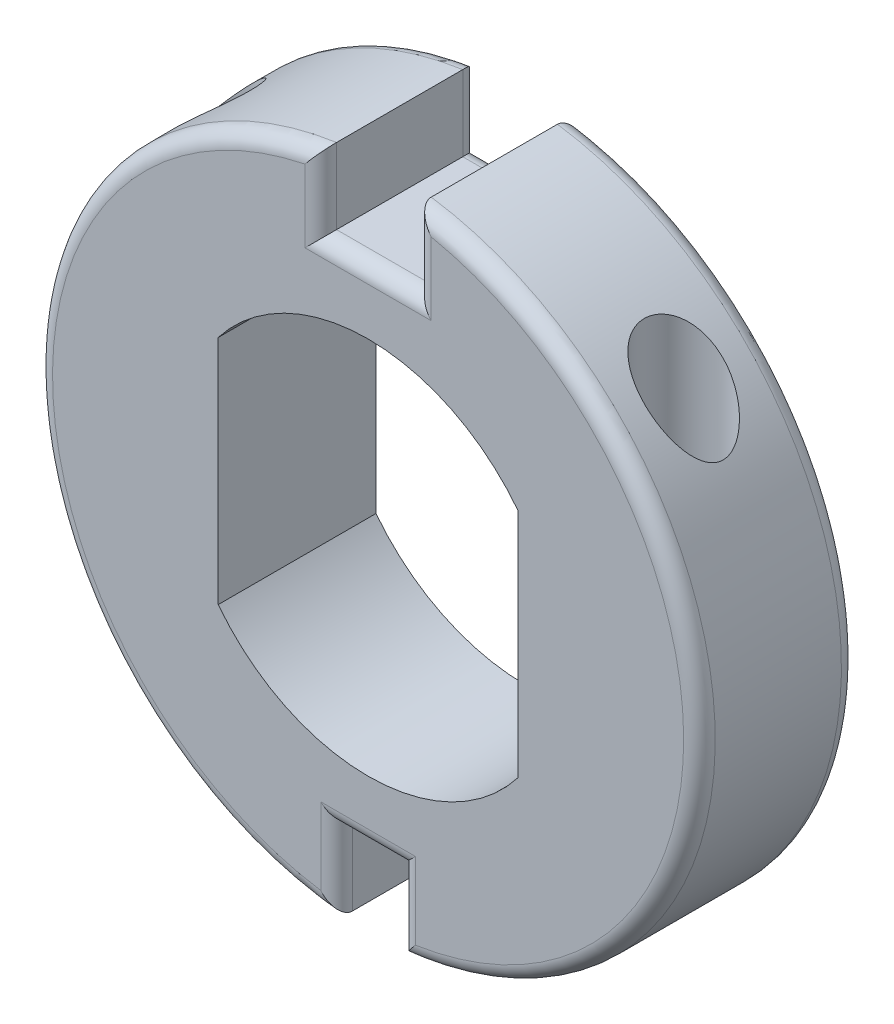
from build123d import *

# Parameters (mm, degrees)
BOSS_EXTRU_1_DEPTH           = 10
ENL_V_MAT_EXTRU_1_DEPTH      = 20
ENL_V_MAT_EXTRU_1_DEPTH_BACK = 10
ESQUISSE2_R                  = 1.25
ENL_V_START                  = 7.5
ESQUISSE2_5_R                = 2.5
ESQUISSE2_5_R_2              = 1.25
ENL_V_MAT_EXTRU_2_DEPTH      = 10
CONG_1_R                     = 1


with BuildPart() as part:
    # Esquisse1 → Boss.-Extru.1 (new body)
    with BuildSketch(Plane.XY):
        with BuildLine():
            Line((3, 20.784609691), (3, 16))
            Line((3, 16), (-3, 16))
            Line((-3, 16), (-3, 20.784609691))
            ThreePointArc((-3, 20.784609691), (-20.993961129, -0.503583277), (-2, -20.90454496))
            Line((-2, -20.90454496), (-2, -15.90454496))
            Line((-2, -15.90454496), (2, -15.90454496))
            Line((2, -15.90454496), (2, -20.90454496))
            ThreePointArc((2, -20.90454496), (20.993961129, -0.503583277), (3, 20.784609691))
        make_face()
        with BuildLine():
            ThreePointArc((-9.5, 7.331439149), (0, 12), (9.5, 7.331439149))
            Line((9.5, 7.331439149), (9.5, -7.331439149))
            ThreePointArc((9.5, -7.331439149), (0, -12), (-9.5, -7.331439149))
            Line((-9.5, -7.331439149), (-9.5, 7.331439149))
        make_face(mode=Mode.SUBTRACT)
    extrude(amount=BOSS_EXTRU_1_DEPTH)

    # Esquisse2 → Enl_v. mat.-Extru.1 (cut, two sides: drawn at the far end of the back side and taken through both)
    with BuildSketch(Plane(origin=(0, 0, 0), x_dir=(1, 0, 0), z_dir=(0, 1, 0)).offset(-ENL_V_MAT_EXTRU_1_DEPTH_BACK)):
        with Locations((15, -5)):
            Circle(ESQUISSE2_R)
        with Locations((-15, -5)):
            Circle(ESQUISSE2_R)
    extrude(amount=ENL_V_MAT_EXTRU_1_DEPTH + ENL_V_MAT_EXTRU_1_DEPTH_BACK, mode=Mode.SUBTRACT)

    # Esquisse2_5 → Enl_v. mat.-Extru.2 (cut)
    # profile 1 of 2: a face of its own
    with BuildSketch(Plane(origin=(0, 0, 0), x_dir=(1, 0, 0), z_dir=(0, 1, 0)).offset(ENL_V_START)):
        with Locations((15, -5)):
            Circle(ESQUISSE2_5_R)
        with Locations((15, -5)):
            Circle(ESQUISSE2_5_R_2, mode=Mode.SUBTRACT)
    # profile 2 of 2: a face of its own
    with BuildSketch(Plane(origin=(0, 0, 0), x_dir=(1, 0, 0), z_dir=(0, 1, 0)).offset(ENL_V_START)):
        with Locations((-15, -5)):
            Circle(ESQUISSE2_5_R)
        with Locations((-15, -5)):
            Circle(ESQUISSE2_5_R_2, mode=Mode.SUBTRACT)
    extrude(amount=ENL_V_MAT_EXTRU_2_DEPTH, mode=Mode.SUBTRACT)

    # Cong_1
    cong_1_edges = [part.edges().sort_by_distance(p)[0] for p in [
        (-2, -18.40454496, 0),
        (0, -15.90454496, 0),
        (2, -18.40454496, 0),
        (-20.993961129, -0.503583277, 0),
        (-3, 18.392304845, 0),
        (0, 16, 0),
        (3, 18.392304845, 0),
        (20.993961129, -0.503583277, 0),
        (-2, -18.40454496, 10),
        (0, -15.90454496, 10),
        (2, -18.40454496, 10),
        (-3, 18.392304845, 10),
        (0, 16, 10),
        (3, 18.392304845, 10),
        (20.993961129, -0.503583277, 10),
        (-20.993961129, -0.503583277, 10),
    ]]
    fillet(cong_1_edges, radius=CONG_1_R)


solid = part.part
